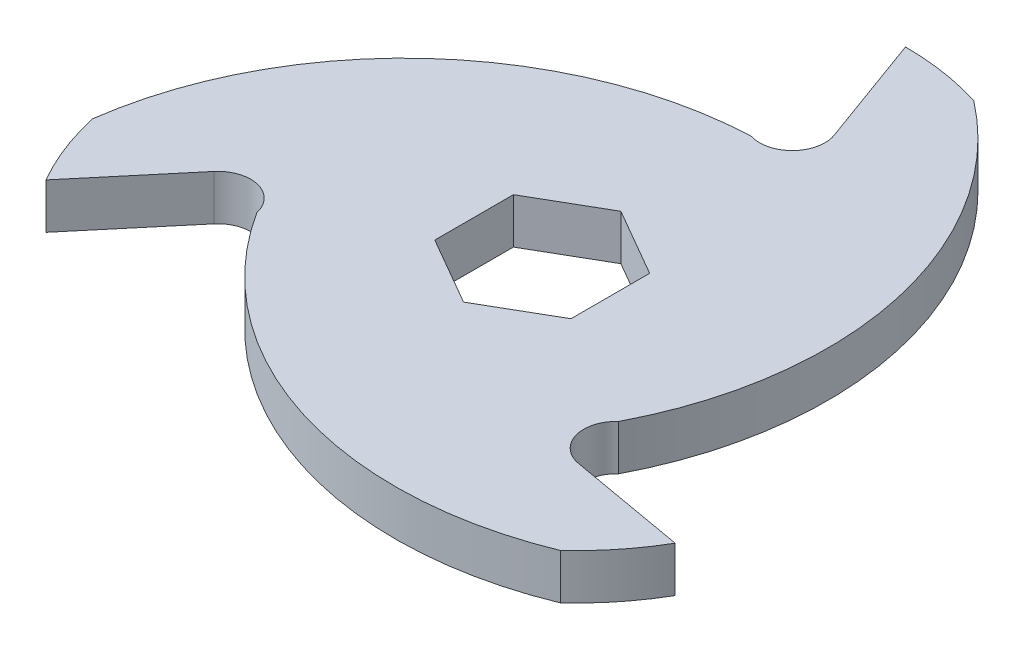
from build123d import *

# Parameters (mm, degrees)
BOSS_EXTRUDE2_DEPTH = 3.175
CUT_EXTRUDE1_DEPTH  = 7.35


with BuildPart() as part:
    # Sketch2 → Boss-Extrude2 (new body, symmetric)
    with BuildSketch(Plane(origin=(0, 0, 0), x_dir=(1, 0, 0), z_dir=(0, 1, 0))):
        with BuildLine():
            Line((0, 50.8), (5.699182497, 35.141624781))
            ThreePointArc((5.699182497, 35.141624781), (4.697625818, 30.400196659), (0, 29.21))
            ThreePointArc((0, 29.21), (-40.712457699, 16.982230342), (-43.994090512, -25.4))
            Line((-43.994090512, -25.4), (-33.283131039, -12.635175567))
            ThreePointArc((-33.283131039, -12.635175567), (-28.676155496, -11.131835033), (-25.296602045, -14.605))
            ThreePointArc((-25.296602045, -14.605), (5.64918596, -43.749137789), (43.994090512, -25.4))
            Line((43.994090512, -25.4), (27.583948542, -22.506449213))
            ThreePointArc((27.583948542, -22.506449213), (23.978529677, -19.268361626), (25.296602045, -14.605))
            ThreePointArc((25.296602045, -14.605), (35.063271738, 26.766907447), (0, 50.8))
        make_face()
        Polygon((0, 10.998522628), (9.525, 5.499261314), (9.525, -5.499261314), (0, -10.998522628), (-9.525, -5.499261314), (-9.525, 5.499261314), align=None, mode=Mode.SUBTRACT)
    extrude(amount=BOSS_EXTRUDE2_DEPTH, both=True)

    # Sketch3 → Cut-Extrude1 (cut, through all)
    with BuildSketch(Plane(origin=(0, 3.175, 0), x_dir=(1, 0, 0), z_dir=(0, 1, 0))):
        with BuildLine():
            ThreePointArc((0, 29.21), (-36.786884898, 21.158593478), (-48.137903328, -14.747595795))
            ThreePointArc((-48.137903328, -14.747595795), (-32.049598102, 15.970797155), (0, 29.21))
        make_face()
        with BuildLine():
            ThreePointArc((11.297159061, 49.062445064), (29.855915106, 19.77036756), (25.296602045, -14.605))
            ThreePointArc((25.296602045, -14.605), (36.717321909, 21.279080109), (11.297159061, 49.062445064))
        make_face()
        with BuildLine():
            ThreePointArc((-25.296602045, -14.605), (0.069562989, -42.437673587), (36.840744267, -34.314849269))
            ThreePointArc((36.840744267, -34.314849269), (2.193682996, -35.741164715), (-25.296602045, -14.605))
        make_face()
    extrude(amount=-CUT_EXTRUDE1_DEPTH, mode=Mode.SUBTRACT)


solid = part.part
